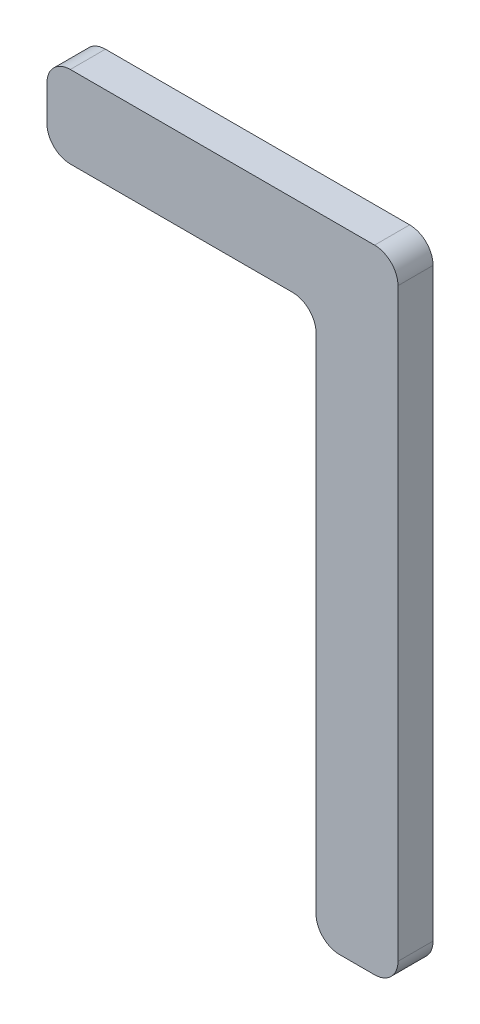
from build123d import *

# Parameters (mm, degrees)
BOSS_EXTRUDE1_DEPTH = 15


with BuildPart() as part:
    # Sketch1 → Boss-Extrude1 (new body)
    with BuildSketch(Plane.XY):
        with BuildLine():
            Line((10, 0), (140, 0))
            ThreePointArc((140, 0), (147.071067812, -2.928932188), (150, -10))
            Line((150, -10), (150, -260))
            ThreePointArc((150, -260), (147.071067812, -267.071067812), (140, -270))
            Line((140, -270), (125, -270))
            ThreePointArc((125, -270), (117.928932188, -267.071067812), (115, -260))
            Line((115, -260), (115, -45))
            ThreePointArc((115, -45), (112.071067812, -37.928932188), (105, -35))
            Line((105, -35), (10, -35))
            ThreePointArc((10, -35), (2.928932188, -32.071067812), (0, -25))
            Line((0, -25), (0, -10))
            ThreePointArc((0, -10), (2.928932188, -2.928932188), (10, 0))
        make_face()
    extrude(amount=BOSS_EXTRUDE1_DEPTH)


solid = part.part
